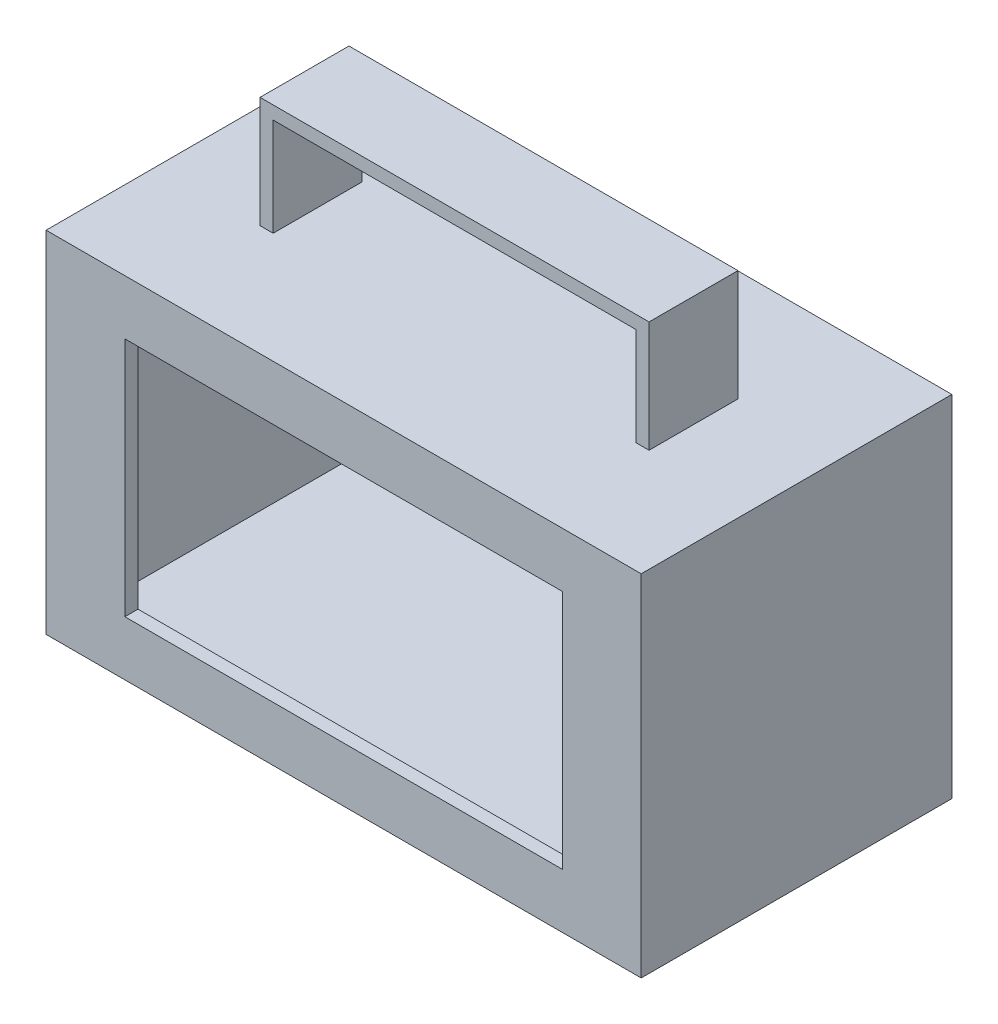
from build123d import *

# Parameters (mm, degrees)
SKETCH1_W           = 136
SKETCH1_H           = 71
BOSS_EXTRUDE2_DEPTH = 80
SHELL5_T            = -3
SKETCH2_W           = 130
SKETCH2_H           = 3
BOSS_EXTRUDE3_DEPTH = 74
BOSS_EXTRUDE4_DEPTH = 10.16
SKETCH7_W           = 100
SKETCH7_H           = 55
CUT_EXTRUDE1_DEPTH  = 10
SKETCH8_W           = 110
SKETCH8_H           = 40
CUT_EXTRUDE2_DEPTH  = 10


with BuildPart() as part:
    # Sketch1 → Boss-Extrude2 (new body)
    with BuildSketch(Plane(origin=(0, 0, 0), x_dir=(1, 0, 0), z_dir=(0, 1, 0))):
        Rectangle(SKETCH1_W, SKETCH1_H)
    extrude(amount=BOSS_EXTRUDE2_DEPTH)

    # Shell5
    shell5_openings = [part.faces().sort_by_distance(p)[0] for p in [
        (0, 40, 35.5),
    ]]
    offset(amount=SHELL5_T, openings=shell5_openings, kind=Kind.INTERSECTION)

    # Sketch2 → Boss-Extrude3 (add)
    with BuildSketch(Plane(origin=(0, 3, 0), x_dir=(1, 0, 0), z_dir=(0, 1, 0))):
        with Locations((0, -34)):
            Rectangle(SKETCH2_W, SKETCH2_H)
    extrude(amount=BOSS_EXTRUDE3_DEPTH)

    # Sketch4 → Boss-Extrude4 (add, symmetric)
    with BuildSketch(Plane.XY):
        Polygon((-44.45, 80), (-44.45, 105.4), (44.45, 105.4), (44.45, 80), (41.45, 80), (41.45, 102.4), (-41.45, 102.4), (-41.45, 80), align=None)
    extrude(amount=BOSS_EXTRUDE4_DEPTH, both=True)

    # Sketch7 → Cut-Extrude1 (cut)
    with BuildSketch(Plane.XY.offset(35.5)):
        with Locations((0, 40)):
            Rectangle(SKETCH7_W, SKETCH7_H)
    extrude(amount=-CUT_EXTRUDE1_DEPTH, mode=Mode.SUBTRACT)

    # Sketch8 → Cut-Extrude2 (cut)
    with BuildSketch(Plane(origin=(0, 0, -35.5), x_dir=(-1, 0, 0), z_dir=(0, 0, -1))):
        with Locations((-1.324990804, 41.229977006)):
            Rectangle(SKETCH8_W, SKETCH8_H)
    extrude(amount=-CUT_EXTRUDE2_DEPTH, mode=Mode.SUBTRACT)


solid = part.part
